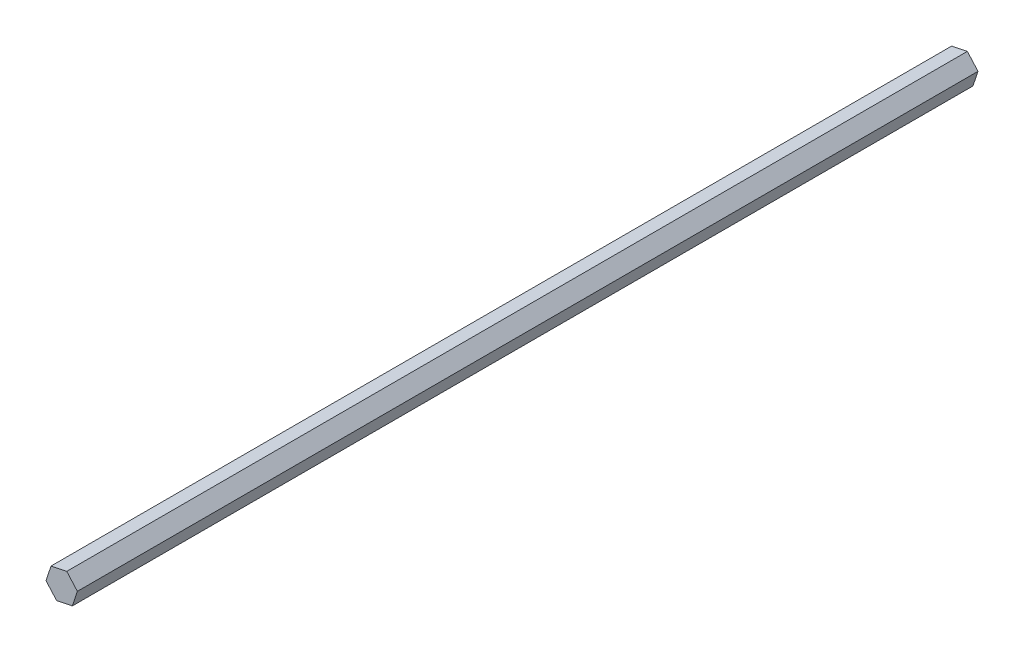
from build123d import *

# Parameters (mm, degrees)
BOSS_EXTRUDE1_DEPTH = 412.242


with BuildPart() as part:
    # Sketch1 → Boss-Extrude1 (new body)
    with BuildSketch(Plane.XY):
        Polygon((4.871347143, -5.480265536), (7.181722745, 1.478577609), (2.310375602, 6.958843145), (-4.871347143, 5.480265536), (-7.181722745, -1.478577609), (-2.310375602, -6.958843145), align=None)
    extrude(amount=BOSS_EXTRUDE1_DEPTH)


solid = part.part
